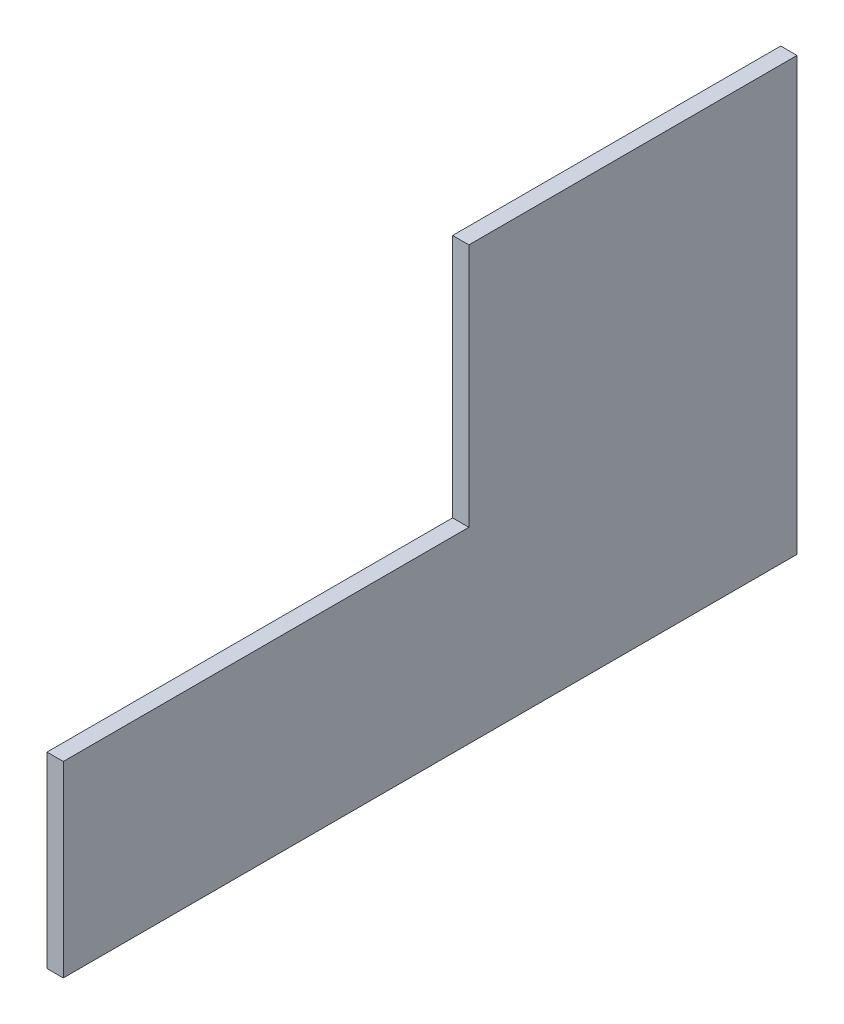
from build123d import *

# Parameters (mm, degrees)
BOSS_EXTRUDE1_DEPTH = 4


with BuildPart() as part:
    # Sketch1 → Boss-Extrude1 (new body)
    with BuildSketch(Plane(origin=(0, 0, 0), x_dir=(0, 0, -1), z_dir=(1, 0, 0))):
        Polygon((9.5, 53), (9.5, -7), (-90, -7), (-90, -53), (90, -53), (90, 53), align=None)
    extrude(amount=-BOSS_EXTRUDE1_DEPTH)


solid = part.part
